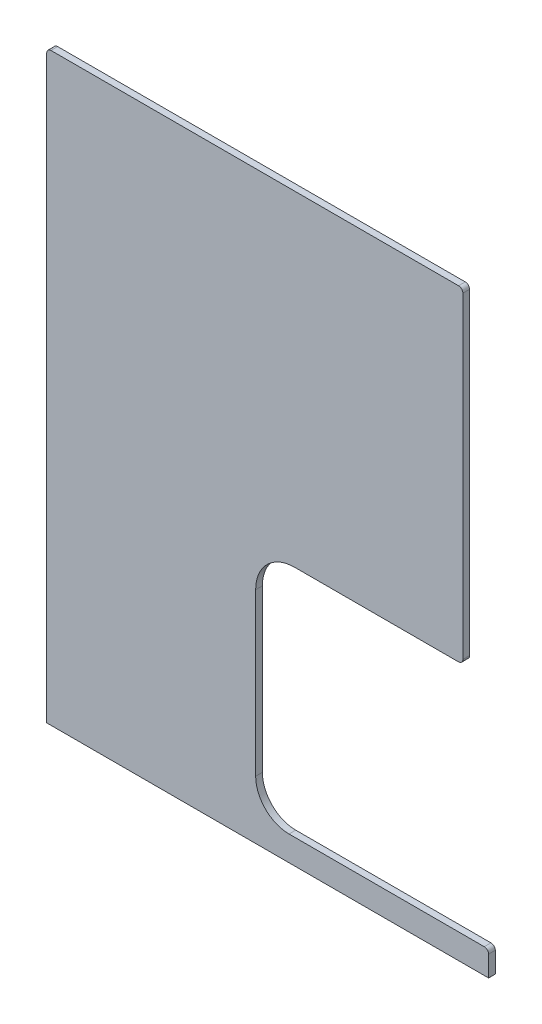
from build123d import *

# Parameters (mm, degrees)
BOSS_EXTRUDE1_DEPTH = 8.6


with BuildPart() as part:
    # Sketch1 → Boss-Extrude1 (new body)
    with BuildSketch(Plane.XY):
        with BuildLine():
            Line((0, 0), (0, 744.5))
            ThreePointArc((0, 744.5), (1.610912703, 748.389087297), (5.5, 750))
            Line((5.5, 750), (528.5, 750))
            ThreePointArc((528.5, 750), (532.389087297, 748.389087297), (534, 744.5))
            Line((534, 744.5), (534, 337.5))
            ThreePointArc((534, 337.5), (532.389087297, 333.610912703), (528.5, 332))
            Line((528.5, 332), (318.1, 332))
            ThreePointArc((318.1, 332), (282.744660941, 317.355339059), (268.1, 282))
            Line((268.1, 282), (268.1, 74.8))
            ThreePointArc((268.1, 74.8), (280.635829765, 44.535829765), (310.9, 32))
            Line((310.9, 32), (313, 32))
            Line((313, 32), (561.5, 32))
            ThreePointArc((561.5, 32), (565.389087297, 30.389087297), (567, 26.5))
            Line((567, 26.5), (567, 0))
            Line((567, 0), (0, 0))
        make_face()
    extrude(amount=BOSS_EXTRUDE1_DEPTH)


solid = part.part
